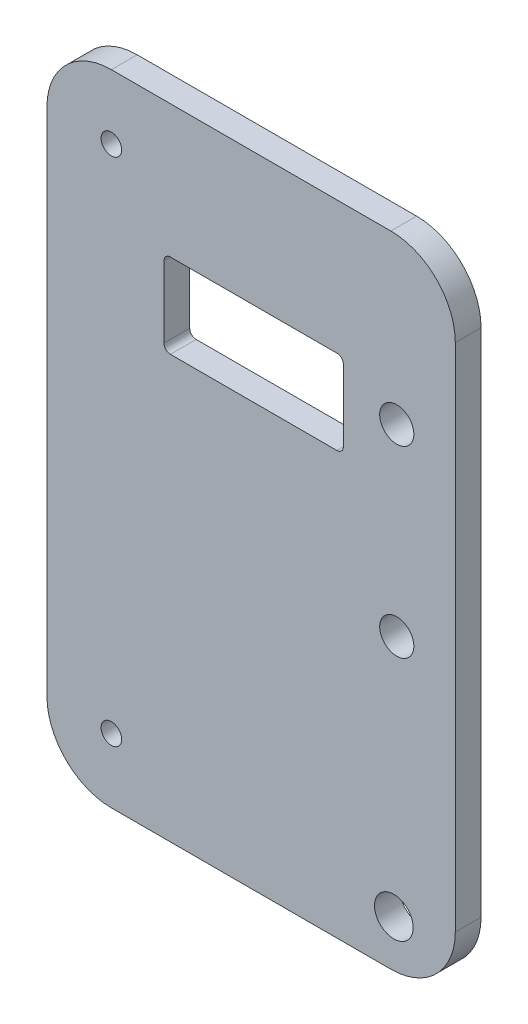
from build123d import *

# Parameters (mm, degrees)
SKETCH1_W            = 63.384201813
SKETCH1_H            = 99.23964582
BOSS_EXTRUDE1_DEPTH  = 4
M5_CLEARANCE_HOLE1_D = 5.3
FILLET1_R            = 10
M5_CLEARANCE_HOLE2_D = 6
M3_CLEARANCE_HOLE1_D = 3.2


with BuildPart() as part:
    # Sketch1 → Boss-Extrude1 (new body)
    with BuildSketch(Plane.XY):
        with Locations((-76.771477461, -317.489186132)):
            Rectangle(SKETCH1_W, SKETCH1_H)
        with BuildLine():
            Line((-63.453357461, -301.557900971), (-89.297127128, -301.557900971))
            ThreePointArc((-89.297127128, -301.557900971), (-90.004233909, -301.265007752), (-90.297127128, -300.557900971))
            Line((-90.297127128, -300.557900971), (-90.297127128, -289.479666407))
            ThreePointArc((-90.297127128, -289.479666407), (-90.004233909, -288.772559625), (-89.297127128, -288.479666407))
            Line((-89.297127128, -288.479666407), (-63.453357461, -288.479666407))
            ThreePointArc((-63.453357461, -288.479666407), (-62.74625068, -288.772559625), (-62.453357461, -289.479666407))
            Line((-62.453357461, -289.479666407), (-62.453357461, -300.557900971))
            ThreePointArc((-62.453357461, -300.557900971), (-62.74625068, -301.265007752), (-63.453357461, -301.557900971))
        make_face(mode=Mode.SUBTRACT)
    extrude(amount=BOSS_EXTRUDE1_DEPTH)

    # M5 Clearance Hole1 (through all)
    with Locations(Plane.XY.offset(4)):
        with Locations((-54.16270611, -321.915681156), (-54.16270611, -293.415681156)):
            Hole(M5_CLEARANCE_HOLE1_D / 2)

    # Fillet1
    fillet1_edges = [part.edges().sort_by_distance(p)[0] for p in [
        (-108.463578367, -267.869363222, 2),
        (-45.079376554, -267.869363222, 2),
        (-45.079376554, -367.109009042, 2),
        (-108.463578367, -367.109009042, 2),
    ]]
    fillet(fillet1_edges, radius=FILLET1_R)

    # M5 Clearance Hole2 (through all)
    with Locations(Plane(origin=(0, 0, 0), x_dir=(-1, 0, 0), z_dir=(0, 0, -1))):
        with Locations((54.617319332, -359.802896905)):
            Hole(M5_CLEARANCE_HOLE2_D / 2)

    # M3 Clearance Hole1 (through all)
    with Locations(Plane.XY.offset(4)):
        with Locations((-98.463578367, -357.109009042), (-98.463578367, -277.869363222)):
            Hole(M3_CLEARANCE_HOLE1_D / 2)


solid = part.part
